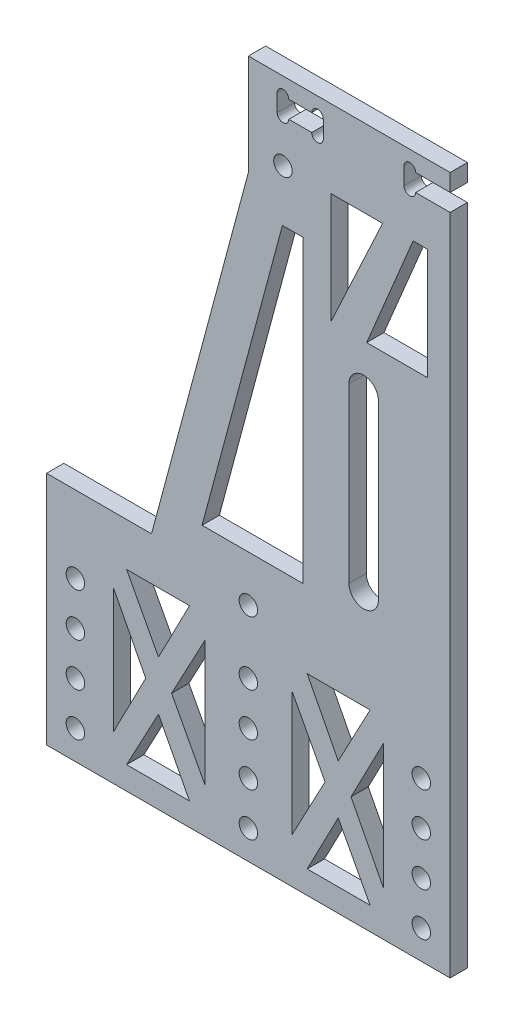
from build123d import *

# Parameters (mm, degrees)
SKETCH_1_R           = 1.6
EXTRUDE_2_DEPTH      = 3
SKETCH_2_W           = 70
SKETCH_2_H           = 20
EXTRUDE_3_DEPTH      = 3
FILLET_1_R           = 40
CUT_EXTRUDE_1_REACH  = 5
SKETCH_4_R           = 1.6
CUT_EXTRUDE_2_REACH  = 5
SKETCH_5_W           = 20
SKETCH_5_H           = 30
SKETCH_6_W           = 3
SKETCH_6_H           = 30
EXTRUDE_1_DEPTH      = 3
SKETCH_7_W           = 20
SKETCH_7_H           = 3
EXTRUDE_2_2_DEPTH    = 3
EXTRUDE_3_2_DEPTH    = 3
CUT_EXTRUDE_3_REACH  = 5
SKETCH_9_W           = 10
SKETCH_9_H           = 40
EXTRUDE_5_DEPTH      = 3
CUT_EXTRUDE_4_REACH  = 5
FILLET_2_R           = 1
SKETCH_13_W          = 70
SKETCH_13_H          = 3
EXTRUDE_4_DEPTH      = 20
SKETCH_14_W          = 8
SKETCH_14_H          = 3
CUT_EXTRUDE_5_DEPTH  = 3
CUT_EXTRUDE_6_REACH  = 5
SKETCH_15_R          = 1.25
CUT_EXTRUDE_7_REACH  = 5
SKETCH_16_R          = 1.6
CUT_EXTRUDE_8_REACH  = 5
SKETCH_17_W          = 60
SKETCH_17_H          = 15
SKETCH_18_W          = 3
SKETCH_18_H          = 15
EXTRUDE_6_DEPTH      = 3
EXTRUDE_8_DEPTH      = 3
SKETCH_20_W          = 2
SKETCH_20_H          = 14.378680804
SKETCH_20_H_2        = 13.161540553
EXTRUDE_9_DEPTH      = 3
CUT_EXTRUDE_9_DEPTH  = 4.0000001
SKETCH_22_W          = 10.058994462
SKETCH_22_H          = 73.690988819
EXTRUDE_5_2_DEPTH    = 3
SKETCH_23_W          = 8
SKETCH_23_H          = 3
EXTRUDE_6_2_DEPTH    = 3
SKETCH_24_R          = 1.005
CUT_EXTRUDE_10_DEPTH = 4.0000001
CUT_EXTRUDE_11_DEPTH = 4.0000001
EXTRUDE_7_DEPTH      = 3
SKETCH_27_R          = 1.6
CUT_EXTRUDE_12_DEPTH = 4
SKETCH_28_W          = 70
SKETCH_28_H          = 6.5
CUT_EXTRUDE_13_DEPTH = 4
EXTRUDE_8_2_DEPTH    = 3
SKETCH_32_R          = 1.6
CUT_EXTRUDE_15_DEPTH = 4


with BuildPart() as part:
    # 草图1 → Extrude 2 (new body)
    with BuildSketch(Plane.XY):
        with BuildLine():
            Line((0, 38.754855538), (-35, 38.754855538))
            Line((-35, 38.754855538), (-35, 13.754855538))
            ThreePointArc((-35, 13.754855538), (-33.535533906, 10.219321632), (-30, 8.754855538))
            Line((-30, 8.754855538), (-5, 8.754855538))
            ThreePointArc((-5, 8.754855538), (-1.464466094, 7.290389444), (0, 3.754855538))
            Line((0, 3.754855538), (0, -1.245144462))
            ThreePointArc((0, -1.245144462), (1.464466094, -4.780678368), (5, -6.245144462))
            Line((5, -6.245144462), (15, -6.245144462))
            ThreePointArc((15, -6.245144462), (20, -11.245144462), (25, -6.245144462))
            Line((25, -6.245144462), (30, -6.245144462))
            ThreePointArc((30, -6.245144462), (33.535533906, -4.780678368), (35, -1.245144462))
            Line((35, -1.245144462), (35, 38.754855538))
            Line((35, 38.754855538), (0, 38.754855538))
        make_face()
        with Locations((0, 13.754855538)):
            Circle(SKETCH_1_R, mode=Mode.SUBTRACT)
        with Locations((-30, 13.754855538)):
            Circle(SKETCH_1_R, mode=Mode.SUBTRACT)
        with Locations((30, 13.754855538)):
            Circle(SKETCH_1_R, mode=Mode.SUBTRACT)
        with Locations((-30, 23.754855538)):
            Circle(SKETCH_1_R, mode=Mode.SUBTRACT)
        with Locations((0, 23.754855538)):
            Circle(SKETCH_1_R, mode=Mode.SUBTRACT)
        with Locations((30, 23.754855538)):
            Circle(SKETCH_1_R, mode=Mode.SUBTRACT)
        with Locations((-30, 33.754855538)):
            Circle(SKETCH_1_R, mode=Mode.SUBTRACT)
        with Locations((0, 33.754855538)):
            Circle(SKETCH_1_R, mode=Mode.SUBTRACT)
        with Locations((30, 33.754855538)):
            Circle(SKETCH_1_R, mode=Mode.SUBTRACT)
        with BuildLine():
            Line((17.45, 33.754855538), (17.45, -6.245144462))
            ThreePointArc((17.45, -6.245144462), (20, -8.795144462), (22.55, -6.245144462))
            Line((22.55, -6.245144462), (22.55, 33.754855538))
            ThreePointArc((22.55, 33.754855538), (20, 36.304855538), (17.45, 33.754855538))
        make_face(mode=Mode.SUBTRACT)
    extrude(amount=EXTRUDE_2_DEPTH)

    # 草图2 → Extrude 3 (add)
    with BuildSketch(Plane.XY.offset(3)):
        with Locations((0, 48.754855538)):
            Rectangle(SKETCH_2_W, SKETCH_2_H)
    extrude(amount=-EXTRUDE_3_DEPTH)

    # 圆角1
    fillet_1_edges = [part.edges().sort_by_distance(p)[0] for p in [
        (25, -6.245144462, 1.5),
        (15, -6.245144462, 1.5),
    ]]
    fillet(fillet_1_edges, radius=FILLET_1_R)

    # 草图4 → 切除-拉伸1 (cut, up to next)
    with BuildSketch(Plane.XY.offset(3), mode=Mode.PRIVATE) as cut_extrude_1_sk1:
        with Locations((-30, 43.754855538)):
            Circle(SKETCH_4_R)
    cut_extrude_1_tool1 = extrude(cut_extrude_1_sk1.sketch, amount=-CUT_EXTRUDE_1_REACH, mode=Mode.PRIVATE) & part.part
    add(cut_extrude_1_tool1.solids().sort_by_distance((-30, 43.754856, 3))[0], mode=Mode.SUBTRACT)
    # 草图4 → 切除-拉伸1 (cut, up to next)
    with BuildSketch(Plane.XY.offset(3), mode=Mode.PRIVATE) as cut_extrude_1_sk2:
        with Locations((0, 43.754855538)):
            Circle(SKETCH_4_R)
    cut_extrude_1_tool2 = extrude(cut_extrude_1_sk2.sketch, amount=-CUT_EXTRUDE_1_REACH, mode=Mode.PRIVATE) & part.part
    add(cut_extrude_1_tool2.solids().sort_by_distance((0, 43.754856, 3))[0], mode=Mode.SUBTRACT)
    # 草图4 → 切除-拉伸1 (cut, up to next)
    with BuildSketch(Plane.XY.offset(3), mode=Mode.PRIVATE) as cut_extrude_1_sk3:
        with Locations((30, 43.754855538)):
            Circle(SKETCH_4_R)
    cut_extrude_1_tool3 = extrude(cut_extrude_1_sk3.sketch, amount=-CUT_EXTRUDE_1_REACH, mode=Mode.PRIVATE) & part.part
    add(cut_extrude_1_tool3.solids().sort_by_distance((30, 43.754856, 3))[0], mode=Mode.SUBTRACT)

    # 草图5 → 切除-拉伸2 (cut, up to next)
    with BuildSketch(Plane.XY.offset(3), mode=Mode.PRIVATE) as cut_extrude_2_sk1:
        with Locations((-15, 28.754855538)):
            Rectangle(SKETCH_5_W, SKETCH_5_H)
    cut_extrude_2_tool1 = extrude(cut_extrude_2_sk1.sketch, amount=-CUT_EXTRUDE_2_REACH, mode=Mode.PRIVATE) & part.part
    add(cut_extrude_2_tool1.solids().sort_by_distance((-15, 28.754856, 3))[0], mode=Mode.SUBTRACT)

    # 草图6 → 拉伸-薄壁1 (add)
    with BuildSketch(Plane.XY.offset(3)):
        with Locations((-15, 28.754855538)):
            Rectangle(SKETCH_6_W, SKETCH_6_H)
    extrude(amount=-EXTRUDE_1_DEPTH)

    # 草图7 → Extrude 2 2 (add)
    with BuildSketch(Plane.XY.offset(3)):
        with Locations((-15, 28.754855538)):
            Rectangle(SKETCH_7_W, SKETCH_7_H)
    extrude(amount=-EXTRUDE_2_2_DEPTH)

    # 草图8 → Extrude 3 2 (add)
    with BuildSketch(Plane(origin=(0, 0, 0), x_dir=(-1, 0, 0), z_dir=(0, 0, -1))):
        Polygon((6.248075442, 12.922805243), (26.248075442, 42.922805243), (23.751924558, 44.586905832), (3.751924558, 14.586905832), align=None)
        Polygon((3.751924558, 42.922805243), (23.751924558, 12.922805243), (26.248075442, 14.586905832), (6.248075442, 44.586905832), align=None)
    extrude(amount=-EXTRUDE_3_2_DEPTH)

    # 草图9 → 切除-拉伸3 (cut, up to next)
    with BuildSketch(Plane.XY.offset(3), mode=Mode.PRIVATE) as cut_extrude_3_sk1:
        with Locations((8.9625, 18.754855538)):
            Rectangle(SKETCH_9_W, SKETCH_9_H)
    cut_extrude_3_tool1 = extrude(cut_extrude_3_sk1.sketch, amount=-CUT_EXTRUDE_3_REACH, mode=Mode.PRIVATE) & part.part
    add(cut_extrude_3_tool1.solids().sort_by_distance((8.9625, 18.754856, 3))[0], mode=Mode.SUBTRACT)

    # 草图11 → Extrude 5 (add)
    with BuildSketch(Plane.XY.offset(3)):
        Polygon((2.90183984, 37.694195354), (11.841179656, 28.75485573), (1.841179656, 18.754855515), (11.841179656, 8.75485573), (2.901839817, -0.184484302), (5.023160183, -2.305804623), (16.083820344, 8.754855776), (6.083820344, 18.75485556), (16.083820344, 28.754855776), (5.02316016, 39.815515721), align=None)
    extrude(amount=-EXTRUDE_5_DEPTH)

    # 草图12 → 切除-拉伸4 (cut, up to next)
    with BuildSketch(Plane(origin=(0, 0, 0), x_dir=(-1, 0, 0), z_dir=(0, 0, -1)), mode=Mode.PRIVATE) as cut_extrude_4_sk1:
        Polygon((-24.720414745, 9.100184733), (-32.811491279, -0.245144462), (-24.720414745, -0.245144462), align=None)
    cut_extrude_4_tool1 = extrude(cut_extrude_4_sk1.sketch, amount=-CUT_EXTRUDE_4_REACH, mode=Mode.PRIVATE) & part.part
    add(cut_extrude_4_tool1.solids().sort_by_distance((27.41744, 2.869965, 0))[0], mode=Mode.SUBTRACT)

    # 圆角2
    fillet_2_edges = [part.edges().sort_by_distance(p)[0] for p in [
        (13.9625, -1.245144462, 1.5),
        (6.083820321, -1.245144462, 1.5),
        (13.9625, 6.633535387, 1.5),
        (24.720414745, 9.100184733, 1.5),
        (32.811491279, -0.245144462, 1.5),
    ]]
    fillet(fillet_2_edges, radius=FILLET_2_R)

    # 草图13 → 凸台-拉伸4 (add)
    with BuildSketch(Plane(origin=(0, 58.754855538, 0), x_dir=(1, 0, 0), z_dir=(0, 1, 0))):
        with Locations((0, -1.5)):
            Rectangle(SKETCH_13_W, SKETCH_13_H)
    extrude(amount=EXTRUDE_4_DEPTH)

    # 草图14 → 切除-拉伸5 (cut)
    with BuildSketch(Plane(origin=(0, 0, 0), x_dir=(-1, 0, 0), z_dir=(0, 0, -1))):
        with Locations((-31, 70.254855538)):
            Rectangle(SKETCH_14_W, SKETCH_14_H)
        with Locations((-9, 70.254855538)):
            Rectangle(SKETCH_14_W, SKETCH_14_H)
    extrude(amount=-CUT_EXTRUDE_5_DEPTH, mode=Mode.SUBTRACT)

    # 草图15 → 切除-拉伸6 (cut, up to next)
    with BuildSketch(Plane.XY.offset(3), mode=Mode.PRIVATE) as cut_extrude_6_sk1:
        with Locations((28.25, 71.754855538)):
            Circle(SKETCH_15_R)
    cut_extrude_6_tool1 = extrude(cut_extrude_6_sk1.sketch, amount=-CUT_EXTRUDE_6_REACH, mode=Mode.PRIVATE) & part.part
    add(cut_extrude_6_tool1.solids().sort_by_distance((28.25, 71.754856, 3))[0], mode=Mode.SUBTRACT)
    # 草图15 → 切除-拉伸6 (cut, up to next)
    with BuildSketch(Plane.XY.offset(3), mode=Mode.PRIVATE) as cut_extrude_6_sk2:
        with Locations((28.25, 68.754855538)):
            Circle(SKETCH_15_R)
    cut_extrude_6_tool2 = extrude(cut_extrude_6_sk2.sketch, amount=-CUT_EXTRUDE_6_REACH, mode=Mode.PRIVATE) & part.part
    add(cut_extrude_6_tool2.solids().sort_by_distance((28.25, 68.754856, 3))[0], mode=Mode.SUBTRACT)
    # 草图15 → 切除-拉伸6 (cut, up to next)
    with BuildSketch(Plane.XY.offset(3), mode=Mode.PRIVATE) as cut_extrude_6_sk3:
        with Locations((6.25, 71.754855538)):
            Circle(SKETCH_15_R)
    cut_extrude_6_tool3 = extrude(cut_extrude_6_sk3.sketch, amount=-CUT_EXTRUDE_6_REACH, mode=Mode.PRIVATE) & part.part
    add(cut_extrude_6_tool3.solids().sort_by_distance((6.25, 71.754856, 3))[0], mode=Mode.SUBTRACT)
    # 草图15 → 切除-拉伸6 (cut, up to next)
    with BuildSketch(Plane.XY.offset(3), mode=Mode.PRIVATE) as cut_extrude_6_sk4:
        with Locations((6.25, 68.754855538)):
            Circle(SKETCH_15_R)
    cut_extrude_6_tool4 = extrude(cut_extrude_6_sk4.sketch, amount=-CUT_EXTRUDE_6_REACH, mode=Mode.PRIVATE) & part.part
    add(cut_extrude_6_tool4.solids().sort_by_distance((6.25, 68.754856, 3))[0], mode=Mode.SUBTRACT)
    # 草图15 → 切除-拉伸6 (cut, up to next)
    with BuildSketch(Plane.XY.offset(3), mode=Mode.PRIVATE) as cut_extrude_6_sk5:
        with Locations((11.75, 71.754855538)):
            Circle(SKETCH_15_R)
    cut_extrude_6_tool5 = extrude(cut_extrude_6_sk5.sketch, amount=-CUT_EXTRUDE_6_REACH, mode=Mode.PRIVATE) & part.part
    add(cut_extrude_6_tool5.solids().sort_by_distance((11.75, 71.754856, 3))[0], mode=Mode.SUBTRACT)
    # 草图15 → 切除-拉伸6 (cut, up to next)
    with BuildSketch(Plane.XY.offset(3), mode=Mode.PRIVATE) as cut_extrude_6_sk6:
        with Locations((11.75, 68.754855538)):
            Circle(SKETCH_15_R)
    cut_extrude_6_tool6 = extrude(cut_extrude_6_sk6.sketch, amount=-CUT_EXTRUDE_6_REACH, mode=Mode.PRIVATE) & part.part
    add(cut_extrude_6_tool6.solids().sort_by_distance((11.75, 68.754856, 3))[0], mode=Mode.SUBTRACT)

    # 草图16 → 切除-拉伸7 (cut, up to next)
    with BuildSketch(Plane.XY.offset(3), mode=Mode.PRIVATE) as cut_extrude_7_sk1:
        with Locations((-30, 70.254855538)):
            Circle(SKETCH_16_R)
    cut_extrude_7_tool1 = extrude(cut_extrude_7_sk1.sketch, amount=-CUT_EXTRUDE_7_REACH, mode=Mode.PRIVATE) & part.part
    add(cut_extrude_7_tool1.solids().sort_by_distance((-30, 70.254856, 3))[0], mode=Mode.SUBTRACT)

    # 草图17 → 切除-拉伸8 (cut, up to next)
    with BuildSketch(Plane(origin=(0, 0, 0), x_dir=(-1, 0, 0), z_dir=(0, 0, -1)), mode=Mode.PRIVATE) as cut_extrude_8_sk1:
        with Locations((0, 57.004855538)):
            Rectangle(SKETCH_17_W, SKETCH_17_H)
    cut_extrude_8_tool1 = extrude(cut_extrude_8_sk1.sketch, amount=-CUT_EXTRUDE_8_REACH, mode=Mode.PRIVATE) & part.part
    add(cut_extrude_8_tool1.solids().sort_by_distance((0, 57.004856, 0))[0], mode=Mode.SUBTRACT)

    # 草图18 → Extrude 6 (add)
    with BuildSketch(Plane(origin=(0, 0, 0), x_dir=(-1, 0, 0), z_dir=(0, 0, -1))):
        with Locations((0, 57.004855538)):
            Rectangle(SKETCH_18_W, SKETCH_18_H)
        Polygon((-31.060660126, 63.44419532), (-16.060658821, 48.44419532), (-13.939338569, 50.565515756), (-28.939339874, 65.565515756), align=None)
        Polygon((16.060661523, 48.444195412), (31.060660218, 63.444195412), (28.939339782, 65.565515663), (13.939341087, 50.565515663), align=None)
    extrude(amount=-EXTRUDE_6_DEPTH)

    # 草图19 → Extrude 8 (add)
    with BuildSketch(Plane(origin=(0, 0, 0), x_dir=(-1, 0, 0), z_dir=(0, 0, -1))):
        Polygon((-2.560660172, 65.565515709), (-17.560660172, 50.565515709), (-15.439339828, 48.444195366), (-0.439339828, 63.444195366), align=None)
        Polygon((0.439339828, 63.444195366), (15.439339828, 48.444195366), (17.560660172, 50.565515709), (2.560660172, 65.565515709), align=None)
    extrude(amount=-EXTRUDE_8_DEPTH)

    # 草图20 → 拉伸-薄壁9 (add)
    with BuildSketch(Plane(origin=(0, 0, 0), x_dir=(-1, 0, 0), z_dir=(0, 0, -1))):
        Polygon((-29.292893219, 48.797748756), (-22.300360013, 55.790281962), (-23.714573576, 57.204495524), (-30.707106781, 50.211962319), align=None)
        Polygon((-0.792893219, 50.211962319), (-7.785426424, 57.204495524), (-9.199639987, 55.790281962), (-2.207106781, 48.797748756), align=None)
        Polygon((2.207106781, 48.797748756), (9.656140344, 56.246782319), (8.241926781, 57.660995881), (0.792893219, 50.211962319), align=None)
        Polygon((30.707106781, 50.211962319), (23.258073219, 57.660995881), (21.843859656, 56.246782319), (29.292893219, 48.797748756), align=None)
        with Locations((15.750000574, 59.565515709)):
            Rectangle(SKETCH_20_W, SKETCH_20_H)
        with Locations((-15.749999426, 58.956946732)):
            Rectangle(SKETCH_20_W, SKETCH_20_H_2)
    extrude(amount=-EXTRUDE_9_DEPTH)

    # 草图21 → 切除-拉伸9 (cut, through all)
    with BuildSketch(Plane(origin=(0, 0, 0), x_dir=(-1, 0, 0), z_dir=(0, 0, -1))):
        with BuildLine():
            Line((-17.45, 55.754855538), (-17.45, 25.754855538))
            ThreePointArc((-17.45, 25.754855538), (-20, 23.204855538), (-22.55, 25.754855538))
            Line((-22.55, 25.754855538), (-22.55, 55.754855538))
            ThreePointArc((-22.55, 55.754855538), (-20, 58.304855538), (-17.45, 55.754855538))
        make_face()
    extrude(amount=-CUT_EXTRUDE_9_DEPTH, mode=Mode.SUBTRACT)

    # 草图22 → Extrude 5 2 (add)
    with BuildSketch(Plane(origin=(0, 0, 0), x_dir=(-1, 0, 0), z_dir=(0, 0, -1))):
        with Locations((-19.690917514, 27.659361129)):
            Rectangle(SKETCH_22_W, SKETCH_22_H)
        with BuildLine():
            Line((-17.45, 25.754855538), (-17.45, 55.754855538))
            ThreePointArc((-17.45, 55.754855538), (-20, 58.304855538), (-22.55, 55.754855538))
            Line((-22.55, 55.754855538), (-22.55, 25.754855538))
            ThreePointArc((-22.55, 25.754855538), (-20, 23.204855538), (-17.45, 25.754855538))
        make_face(mode=Mode.SUBTRACT)
    extrude(amount=-EXTRUDE_5_2_DEPTH)

    # 草图23 → Extrude 6 2 (add)
    with BuildSketch(Plane(origin=(0, 0, 0), x_dir=(-1, 0, 0), z_dir=(0, 0, -1))):
        Polygon((-35, 67.504855538), (0, 67.504855538), (0, 96.254855538), (-35, 96.254855538), (-35, 93.254855538), (-27, 93.254855538), (-27, 90.254855538), (-35, 90.254855538), align=None)
        with Locations((-9, 91.754855538)):
            Rectangle(SKETCH_23_W, SKETCH_23_H, mode=Mode.SUBTRACT)
    extrude(amount=-EXTRUDE_6_2_DEPTH)

    # 草图24 → 切除-拉伸10 (cut, through all)
    with BuildSketch(Plane(origin=(0, 0, 0), x_dir=(-1, 0, 0), z_dir=(0, 0, -1))):
        with Locations((-28.005, 93.254855538)):
            Circle(SKETCH_24_R)
        with Locations((-28.005, 90.254855538)):
            Circle(SKETCH_24_R)
        with Locations((-11.995, 93.254855538)):
            Circle(SKETCH_24_R)
        with Locations((-11.995, 90.254855538)):
            Circle(SKETCH_24_R)
        with Locations((-6.005, 90.254855538)):
            Circle(SKETCH_24_R)
        with Locations((-6.005, 93.254855538)):
            Circle(SKETCH_24_R)
    extrude(amount=-CUT_EXTRUDE_10_DEPTH, mode=Mode.SUBTRACT)

    # 草图25 → 切除-拉伸11 (cut, through all)
    with BuildSketch(Plane(origin=(0, 0, 0), x_dir=(-1, 0, 0), z_dir=(0, 0, -1))):
        Polygon((-25.460220745, 69.504855538), (-9.539779255, 69.504855538), (-17.5, 75.156612267), align=None)
        Polygon((-30, 69.504855538), (-30, 85.254855538), (-19.5, 76.959855538), align=None)
        Polygon((-25.160499416, 85.254855538), (-9.839500584, 85.254855538), (-17.5, 79.203060999), align=None)
        Polygon((-5, 69.504855538), (-5, 85.254855538), (-15.5, 76.959855538), align=None)
    extrude(amount=-CUT_EXTRUDE_11_DEPTH, mode=Mode.SUBTRACT)

    # 草图26 → 凸台-拉伸7 (add)
    with BuildSketch(Plane(origin=(0, 0, 0), x_dir=(-1, 0, 0), z_dir=(0, 0, -1))):
        with BuildLine():
            Line((35, 13.754855538), (31.6, 13.754855538))
            ThreePointArc((31.6, 13.754855538), (30, 12.154855538), (28.4, 13.754855538))
            Line((28.4, 13.754855538), (1.6, 13.754855538))
            ThreePointArc((1.6, 13.754855538), (0, 12.154855538), (-1.6, 13.754855538))
            Line((-1.6, 13.754855538), (-28.4, 13.754855538))
            ThreePointArc((-28.4, 13.754855538), (-30, 12.154855538), (-31.6, 13.754855538))
            Line((-31.6, 13.754855538), (-35, 13.754855538))
            Line((-35, 13.754855538), (-35, -31.245144462))
            Line((-35, -31.245144462), (35, -31.245144462))
            Line((35, -31.245144462), (35, 13.754855538))
        make_face()
    extrude(amount=-EXTRUDE_7_DEPTH)

    # 草图27 → 切除-拉伸12 (cut, through all)
    with BuildSketch(Plane(origin=(0, 0, 0), x_dir=(-1, 0, 0), z_dir=(0, 0, -1))):
        with Locations((-30, 13.754855538)):
            Circle(SKETCH_27_R)
        with Locations((0, 13.754855538)):
            Circle(SKETCH_27_R)
        with Locations((30, 13.754855538)):
            Circle(SKETCH_27_R)
        with Locations((-30, 2.754855538)):
            Circle(SKETCH_27_R)
        with Locations((0, 2.754855538)):
            Circle(SKETCH_27_R)
        with Locations((30, 2.754855538)):
            Circle(SKETCH_27_R)
        with Locations((-30, -4.745144462)):
            Circle(SKETCH_27_R)
        with Locations((0, -4.745144462)):
            Circle(SKETCH_27_R)
        with Locations((30, -4.745144462)):
            Circle(SKETCH_27_R)
        with Locations((-30, -12.245144462)):
            Circle(SKETCH_27_R)
        with Locations((0, -12.245144462)):
            Circle(SKETCH_27_R)
        with Locations((30, -12.245144462)):
            Circle(SKETCH_27_R)
        with Locations((-30, -19.745144462)):
            Circle(SKETCH_27_R)
        with Locations((0, -19.745144462)):
            Circle(SKETCH_27_R)
        with Locations((30, -19.745144462)):
            Circle(SKETCH_27_R)
    extrude(amount=-CUT_EXTRUDE_12_DEPTH, mode=Mode.SUBTRACT)

    # 草图28 → 切除-拉伸13 (cut, through all)
    with BuildSketch(Plane(origin=(0, 0, 0), x_dir=(-1, 0, 0), z_dir=(0, 0, -1))):
        with Locations((0, -27.995144462)):
            Rectangle(SKETCH_28_W, SKETCH_28_H)
        Polygon((21.115641359, 8.57522588), (10.206883688, 8.57522588), (15.587221181, -1.839922846), align=None)
        Polygon((23.418601311, 4.696556486), (23.418601311, -16.999750437), (17.80126769, -6.12582939), align=None)
        Polygon((21.115641359, -20.757211413), (10.206883688, -20.757211413), (15.587221181, -10.391423581), align=None)
        Polygon((7.540298479, 4.696556486), (7.540298479, -16.999750437), (13.312237613, -6.12582939), align=None)
        Polygon((-15.587221181, -10.391423581), (-10.206883688, -20.757211413), (-21.115641359, -20.757211413), align=None)
        Polygon((-13.312237613, -6.12582939), (-7.540298479, -16.999750437), (-7.540298479, 4.696556486), align=None)
        Polygon((-17.80126769, -6.12582939), (-23.418601311, -16.999750437), (-23.418601311, 4.696556486), align=None)
        Polygon((-21.115641359, 8.57522588), (-15.587221181, -1.839922846), (-10.206883688, 8.57522588), align=None)
    extrude(amount=-CUT_EXTRUDE_13_DEPTH, mode=Mode.SUBTRACT)

    # 草图31 → Extrude 8 2 (add)
    with BuildSketch(Plane.XY.offset(3)):
        Polygon((-35, 78.754855538), (-35, 9.873710658), (-4.007403078, 9.873710658), (-4.007403078, 17.053641173), (2.83857718, 17.053641173), (2.83857718, 9.873710658), (15.695662056, 9.873710658), (15.695662056, 61.469025289), (23.209542827, 61.469025289), (23.209542827, 9.873710658), (35, 9.873710658), (35, 86.682269655), (0, 86.682269655), (0, 78.754855538), align=None)
    extrude(amount=-EXTRUDE_8_2_DEPTH)

    # 草图32 → 切除-拉伸15 (cut, through all)
    with BuildSketch(Plane.XY.offset(3)):
        with Locations((6, 82.754855538)):
            Circle(SKETCH_32_R)
        Polygon((0, 78.754855538), (-16.794956149, 16.07522588), (-35, 16.07522588), (-35, 78.754855538), align=None)
        Polygon((5.907187301, 73.754855538), (-8.026170706, 21.754855538), (9.45, 21.754855538), (9.45, 73.754855538), align=None)
        Polygon((14.311788093, 82.754855538), (14.311788093, 63.468593359), (23.28406303, 82.754855538), align=None)
        Polygon((28.575404659, 82.754855538), (20.523363049, 63.468593359), (31.106046308, 63.468593359), (31.106046308, 82.754855538), align=None)
    extrude(amount=-CUT_EXTRUDE_15_DEPTH, mode=Mode.SUBTRACT)


solid = part.part
